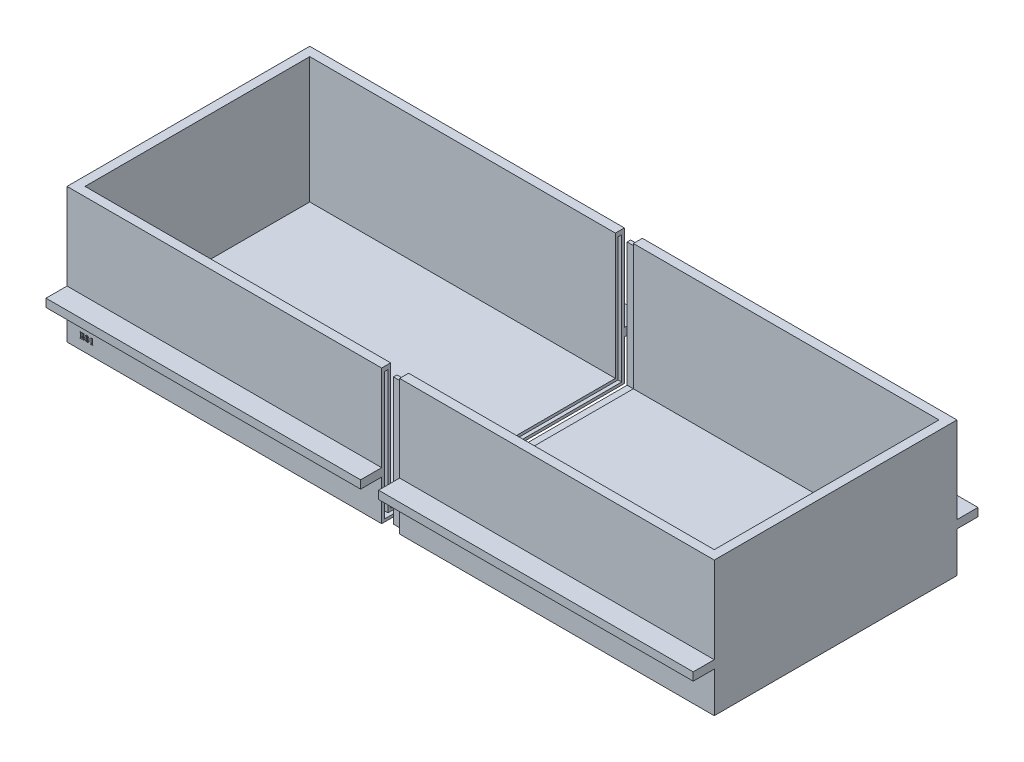
from build123d import *

# Parameters (mm, degrees)
SKETCH1_W                     = 175
SKETCH1_H                     = 135
BOSS_EXTRUDE2_DEPTH           = 75
SKETCH3_W                     = 170
SKETCH3_H                     = 125
CUT_EXTRUDE3_DEPTH            = 70
EXTRUDE_THIN4_DEPTH           = 5
EXTRUDE_THIN4_TAPER           = 0.5
EXTRUDE_THIN4_OTHER_WAY_DEPTH = 1
EXTRUDE_THIN4_OTHER_WAY_TAPER = 1
CUT_EXTRUDE_THIN1_DEPTH       = 241.987551546
CUT_EXTRUDE_THIN1_DEPTH_BACK  = 5
CUT_EXTRUDE6_DEPTH            = 10
SKETCH15_W                    = 175
SKETCH15_H                    = 4.5
BOSS_EXTRUDE3_DEPTH           = 11.7
SKETCH16_W                    = 175
SKETCH16_H                    = 4.5
BOSS_EXTRUDE4_DEPTH           = 11.7
SKETCH17_W                    = 175
SKETCH17_H                    = 4.503667067
BOSS_EXTRUDE5_DEPTH           = 11.7
SKETCH18_W                    = 175
SKETCH18_H                    = 4.5
BOSS_EXTRUDE6_DEPTH           = 11.7


with BuildPart() as part:
    # Sketch1 → Boss-Extrude2 (new body)
    with BuildSketch(Plane(origin=(0, 0, 0), x_dir=(1, 0, 0), z_dir=(0, 1, 0))):
        with Locations((87.5, 67.5)):
            Rectangle(SKETCH1_W, SKETCH1_H)
    extrude(amount=BOSS_EXTRUDE2_DEPTH)

    # Sketch3 → Cut-Extrude3 (cut)
    with BuildSketch(Plane(origin=(0, 75, 0), x_dir=(1, 0, 0), z_dir=(0, 1, 0))):
        with Locations((85, 67.5)):
            Rectangle(SKETCH3_W, SKETCH3_H)
    extrude(amount=-CUT_EXTRUDE3_DEPTH, mode=Mode.SUBTRACT)


with BuildPart() as body_2:
    # Sketch5 → Extrude-Thin4 (new body)
    with BuildSketch(Plane.ZY):
        Polygon((-133.5, 72.5), (-133.5, 1.5), (-1.5, 1.5), (-1.5, 72.5), (-3.5, 72.5), (-3.5, 3.5), (-131.5, 3.5), (-131.5, 72.5), align=None)
    extrude(amount=EXTRUDE_THIN4_DEPTH, taper=EXTRUDE_THIN4_TAPER)

    # Sketch5 → Extrude-Thin4 other way (add)
    with BuildSketch(Plane.ZY):
        Polygon((-133.5, 72.5), (-133.5, 1.5), (-1.5, 1.5), (-1.5, 72.5), (-3.5, 72.5), (-3.5, 3.5), (-131.5, 3.5), (-131.5, 72.5), align=None)
    extrude(amount=-EXTRUDE_THIN4_OTHER_WAY_DEPTH, taper=EXTRUDE_THIN4_OTHER_WAY_TAPER)


with BuildPart() as body_3:
    # Mirror7: mirrored copy
    add(part.part.mirror(Plane(origin=(-5, 0, 0), x_dir=(0, 0, 1), z_dir=(1, 0, 0))))

    # Sketch11 → Cut-Extrude-Thin1 (cut, two sides)
    with BuildSketch(Plane(origin=(-10, 0, 0), x_dir=(0, 0, -1), z_dir=(1, 0, 0))) as cut_extrude_thin1_sk:
        Polygon((1.5, 72.5), (1.5, 1.5), (133.5, 1.5), (133.5, 72.5), (131.5, 72.5), (131.5, 3.5), (3.5, 3.5), (3.5, 72.5), align=None)
    extrude(amount=CUT_EXTRUDE_THIN1_DEPTH, mode=Mode.SUBTRACT)
    extrude(cut_extrude_thin1_sk.sketch, amount=-CUT_EXTRUDE_THIN1_DEPTH_BACK, mode=Mode.SUBTRACT)

    # Sketch13 → Cut-Extrude6 (cut)
    with BuildSketch(Plane.XY):
        with BuildLine():
            Line((-176.616440921, 8.671071982), (-176.616440921, 5.496071982))
            Line((-176.616440921, 5.496071982), (-177.632744089, 5.496071982))
            Line((-177.632744089, 5.496071982), (-177.69337777, 5.496071982))
            add(Edge.make_bspline(
                [(-177.69337777, 5.496071982), (-177.705346361, 5.496468009), (-177.727817325, 5.497211546), (-177.759638375, 5.502718408), (-177.787428818, 5.511979197), (-177.810534198, 5.526028336), (-177.829467076, 5.543433336), (-177.841486357, 5.565357563), (-177.84978866, 5.589882566), (-177.85068737, 5.607384741), (-177.851163143, 5.616650324)],
                knots=[0, 0, 0, 0, 1.275809178, 2.395324508, 3.433364274, 4.378530456, 5.262016052, 6.140052186, 7.015350866, 8, 8, 8, 8], degree=3))
            add(Edge.make_bspline(
                [(-177.851163143, 5.616650324), (-177.850225743, 5.631292422), (-177.848462527, 5.658833677), (-177.831922046, 5.696412103), (-177.803015925, 5.725115324), (-177.778161044, 5.735747942), (-177.765035756, 5.741362781)],
                knots=[0, 0, 0, 0, 1.074896783, 2.021841926, 2.955380476, 4, 4, 4, 4], degree=3))
            add(Edge.make_bspline(
                [(-177.765035756, 5.741362781), (-177.754225698, 5.745222157), (-177.735340256, 5.751964584), (-177.710892127, 5.761296952), (-177.693740648, 5.767252992), (-177.679844251, 5.772605459), (-177.667198156, 5.782716064), (-177.660632574, 5.793210124), (-177.656859758, 5.799240385)],
                knots=[0, 0, 0, 0, 1.641128884, 2.867093284, 3.73955991, 4.239698614, 4.988468111, 6, 6, 6, 6], degree=3))
            add(Edge.make_bspline(
                [(-177.656859758, 5.799240385), (-177.652637239, 5.80621605), (-177.643541415, 5.821242492), (-177.636021582, 5.848683029), (-177.631072029, 5.881041958), (-177.63081585, 5.904403527), (-177.630677032, 5.917062651)],
                knots=[0, 0, 0, 0, 0.795728394, 1.714096871, 2.761318972, 4, 4, 4, 4], degree=3))
            Line((-177.630677032, 5.917062651), (-177.630677032, 8.241813085))
            add(Edge.make_bspline(
                [(-177.630677032, 8.241813085), (-177.630845333, 8.25469561), (-177.631159324, 8.27872999), (-177.635821171, 8.311842767), (-177.643707699, 8.339841156), (-177.652652572, 8.355177866), (-177.656859758, 8.362391427)],
                knots=[0, 0, 0, 0, 1.234380862, 2.302932019, 3.201790819, 4, 4, 4, 4], degree=3))
            add(Edge.make_bspline(
                [(-177.656859758, 8.362391427), (-177.660634584, 8.368416389), (-177.667203662, 8.378901229), (-177.679830806, 8.389061808), (-177.693859505, 8.394296275), (-177.710689479, 8.401327562), (-177.735390239, 8.410224655), (-177.754243893, 8.417050771), (-177.765035756, 8.42095805)],
                knots=[0, 0, 0, 0, 1.009569614, 1.75688657, 2.256055053, 3.138468602, 4.362054748, 6, 6, 6, 6], degree=3))
            add(Edge.make_bspline(
                [(-177.765035756, 8.42095805), (-177.778235914, 8.426499261), (-177.80353883, 8.437121013), (-177.831730258, 8.467367626), (-177.848499642, 8.50553328), (-177.85023882, 8.533541183), (-177.851163143, 8.548426583)],
                knots=[0, 0, 0, 0, 1.03007389, 1.974512116, 2.923511095, 4, 4, 4, 4], degree=3))
            add(Edge.make_bspline(
                [(-177.851163143, 8.548426583), (-177.850676236, 8.557914987), (-177.849755691, 8.575853743), (-177.841650305, 8.600924709), (-177.829447523, 8.62300435), (-177.810556115, 8.640476305), (-177.787286248, 8.654313018), (-177.759802576, 8.664649997), (-177.727791348, 8.669861277), (-177.705337334, 8.670651232), (-177.69337777, 8.671071982)],
                knots=[0, 0, 0, 0, 1.002003185, 1.894384998, 2.766311233, 3.643649008, 4.582238159, 5.621343591, 6.733068665, 8, 8, 8, 8], degree=3))
            Line((-177.69337777, 8.671071982), (-177.632744089, 8.671071982))
            Line((-177.632744089, 8.671071982), (-176.616440921, 8.671071982))
        make_face()
        with BuildLine():
            Line((-176.39595481, 8.671071982), (-175.469913143, 8.671071982))
            Line((-175.469913143, 8.671071982), (-175.469913143, 7.835291818))
            add(Edge.make_bspline(
                [(-175.469913143, 7.835291818), (-175.469958391, 7.82422301), (-175.47004206, 7.803755679), (-175.476131302, 7.775622906), (-175.483686783, 7.751518287), (-175.496452521, 7.732339788), (-175.513083454, 7.717716752), (-175.533749451, 7.708393076), (-175.557931838, 7.701759599), (-175.575507403, 7.701222533), (-175.584979332, 7.700933094)],
                knots=[0, 0, 0, 0, 1.297100046, 2.398467488, 3.37194797, 4.248080405, 5.071011418, 5.940462097, 6.890061477, 8, 8, 8, 8], degree=3))
            add(Edge.make_bspline(
                [(-175.584979332, 7.700933094), (-175.599506049, 7.701826732), (-175.625285577, 7.70341261), (-175.656259278, 7.716301713), (-175.670731633, 7.736387977), (-175.682057286, 7.755357101), (-175.692689619, 7.779977349), (-175.698823646, 7.798492596), (-175.702112579, 7.808420073)],
                knots=[0, 0, 0, 0, 1.496408907, 2.655570162, 3.259085196, 3.998612629, 4.926899124, 6, 6, 6, 6], degree=3))
            add(Edge.make_bspline(
                [(-175.702112579, 7.808420073), (-175.717383026, 7.851565123), (-175.746685576, 7.934356409), (-175.805763599, 8.047562724), (-175.875482195, 8.14433391), (-175.956282018, 8.225500112), (-176.048388272, 8.291272803), (-176.153248274, 8.341023254), (-176.269945451, 8.37747089), (-176.352986897, 8.388874688), (-176.39595481, 8.394775324)],
                knots=[0, 0, 0, 0, 1.130832012, 2.169960077, 3.145894403, 4.069657363, 4.990096479, 5.930045021, 6.928948727, 8, 8, 8, 8], degree=3))
            Line((-176.39595481, 8.394775324), (-176.39595481, 8.671071982))
        make_face()
        with BuildLine():
            Line((-176.39595481, 6.969883831), (-176.39595481, 7.23791226))
            add(Edge.make_bspline(
                [(-176.39595481, 7.23791226), (-176.375624758, 7.248939951), (-176.336763637, 7.270019505), (-176.28314459, 7.303654051), (-176.239423442, 7.340991464), (-176.202037314, 7.37924492), (-176.172552935, 7.423286505), (-176.146985625, 7.472111578), (-176.126386726, 7.527783946), (-176.116513722, 7.567383139), (-176.111389922, 7.587933962)],
                knots=[0, 0, 0, 0, 1.180986571, 2.257469038, 3.222785507, 4.110265038, 4.978639913, 5.917385587, 6.919184056, 8, 8, 8, 8], degree=3))
            add(Edge.make_bspline(
                [(-176.111389922, 7.587933962), (-176.108439891, 7.601784296), (-176.10302178, 7.627222216), (-176.091776741, 7.661538358), (-176.080041894, 7.689242559), (-176.065656379, 7.710734772), (-176.048528802, 7.726333504), (-176.028889141, 7.737762968), (-176.005877856, 7.744004675), (-175.989700178, 7.744676095), (-175.981165313, 7.745030316)],
                knots=[0, 0, 0, 0, 1.505392146, 2.764846178, 3.836585285, 4.697326174, 5.492824879, 6.280783141, 7.092991927, 8, 8, 8, 8], degree=3))
            add(Edge.make_bspline(
                [(-175.981165313, 7.745030316), (-175.970006097, 7.74459074), (-175.948796907, 7.743755283), (-175.920199104, 7.731421745), (-175.897180749, 7.711675982), (-175.887625901, 7.694208562), (-175.882635582, 7.685085654)],
                knots=[0, 0, 0, 0, 1.085852217, 2.06376913, 2.988742716, 4, 4, 4, 4], degree=3))
            add(Edge.make_bspline(
                [(-175.882635582, 7.685085654), (-175.880102235, 7.678255391), (-175.873999653, 7.661801968), (-175.87050041, 7.630934039), (-175.866525384, 7.590799772), (-175.866694213, 7.560624885), (-175.866788143, 7.543836739)],
                knots=[0, 0, 0, 0, 0.609895254, 1.469176849, 2.591947466, 4, 4, 4, 4], degree=3))
            Line((-175.866788143, 7.543836739), (-175.866788143, 6.662581314))
            add(Edge.make_bspline(
                [(-175.866788143, 6.662581314), (-175.867030855, 6.645581407), (-175.867477796, 6.614277017), (-175.871124013, 6.571273225), (-175.8784172, 6.536744385), (-175.888411984, 6.509478405), (-175.903667118, 6.489636004), (-175.923581251, 6.47578978), (-175.948393231, 6.467484627), (-175.96662751, 6.466653611), (-175.976342179, 6.466210871)],
                knots=[0, 0, 0, 0, 1.58411055, 2.917051989, 4.012593196, 4.866950163, 5.598911493, 6.305405458, 7.097171608, 8, 8, 8, 8], degree=3))
            add(Edge.make_bspline(
                [(-175.976342179, 6.466210871), (-175.992120064, 6.467577387), (-176.022236, 6.470185715), (-176.054939347, 6.492695077), (-176.07264477, 6.518745618), (-176.084777982, 6.543694393), (-176.096025184, 6.573881108), (-176.101528266, 6.59613338), (-176.104499731, 6.608148805)],
                knots=[0, 0, 0, 0, 1.342036637, 2.56160375, 3.240040044, 4.033620071, 4.938225671, 6, 6, 6, 6], degree=3))
            add(Edge.make_bspline(
                [(-176.104499731, 6.608148805), (-176.110842747, 6.633582213), (-176.122961309, 6.682173669), (-176.148805335, 6.748868298), (-176.177146725, 6.807156283), (-176.211505697, 6.855443919), (-176.250097298, 6.89558473), (-176.293281902, 6.928621015), (-176.342360627, 6.953879374), (-176.377832599, 6.964472122), (-176.39595481, 6.969883831)],
                knots=[0, 0, 0, 0, 1.278531199, 2.442680666, 3.485773606, 4.434753066, 5.322955403, 6.195374153, 7.078038041, 8, 8, 8, 8], degree=3))
        make_face()
        with BuildLine():
            Line((-176.39595481, 5.496071982), (-176.39595481, 5.752387087))
            add(Edge.make_bspline(
                [(-176.39595481, 5.752387087), (-176.371802756, 5.756545681), (-176.325358431, 5.764542646), (-176.259158789, 5.779314158), (-176.199715053, 5.797538584), (-176.145046604, 5.817263003), (-176.094583054, 5.843226445), (-176.044362369, 5.872961138), (-175.994487177, 5.908635095), (-175.962381882, 5.935672116), (-175.946025339, 5.949446548)],
                knots=[0, 0, 0, 0, 1.178424117, 2.266106011, 3.258322885, 4.167001624, 5.056005255, 5.982165939, 6.971982955, 8, 8, 8, 8], degree=3))
            add(Edge.make_bspline(
                [(-175.946025339, 5.949446548), (-175.914990278, 5.978409283), (-175.85573781, 6.033705242), (-175.794976321, 6.114593429), (-175.754977887, 6.183556307), (-175.726849976, 6.242312699), (-175.698554906, 6.307887163), (-175.681853376, 6.354941071), (-175.673173777, 6.379394465)],
                knots=[0, 0, 0, 0, 1.478913818, 2.823557948, 3.509390326, 4.258413643, 5.094916917, 6, 6, 6, 6], degree=3))
            add(Edge.make_bspline(
                [(-175.673173777, 6.379394465), (-175.668953175, 6.391160153), (-175.661157695, 6.412891461), (-175.648341811, 6.442223181), (-175.634617881, 6.465125982), (-175.616341175, 6.48808462), (-175.585093693, 6.507149), (-175.557026785, 6.509219013), (-175.542260148, 6.510308094)],
                knots=[0, 0, 0, 0, 1.119865357, 2.068399023, 2.86239926, 3.505232302, 4.687446157, 6, 6, 6, 6], degree=3))
            add(Edge.make_bspline(
                [(-175.542260148, 6.510308094), (-175.532130163, 6.509707605), (-175.513212385, 6.50858619), (-175.486829232, 6.502294364), (-175.465877099, 6.489253454), (-175.449665696, 6.470885873), (-175.439008257, 6.446047246), (-175.430754245, 6.41524378), (-175.426329329, 6.37721835), (-175.425995901, 6.349545644), (-175.425815921, 6.334608224)],
                knots=[0, 0, 0, 0, 0.999578033, 1.866714988, 2.638932701, 3.392362113, 4.242509345, 5.27434009, 6.528718957, 8, 8, 8, 8], degree=3))
            Line((-175.425815921, 6.334608224), (-175.425815921, 5.496071982))
            Line((-175.425815921, 5.496071982), (-176.39595481, 5.496071982))
        make_face()
        with BuildLine():
            add(Edge.make_bspline(
                [(-174.01470481, 5.457486913), (-174.054356273, 5.463376377), (-174.131889647, 5.47489247), (-174.24390388, 5.504964767), (-174.348760088, 5.545073959), (-174.448074077, 5.594420466), (-174.54214204, 5.65489762), (-174.63105306, 5.728416516), (-174.717999568, 5.812395184), (-174.770479837, 5.876086463), (-174.797430504, 5.908794422)],
                knots=[0, 0, 0, 0, 1.034782028, 2.023384117, 2.988532632, 3.930372206, 4.883152863, 5.869902034, 6.906111536, 8, 8, 8, 8], degree=3))
            add(Edge.make_bspline(
                [(-174.797430504, 5.908794422), (-174.826313554, 5.947029194), (-174.88450205, 6.024057896), (-174.956720633, 6.151422436), (-175.020296858, 6.287062087), (-175.071108496, 6.432469923), (-175.112444577, 6.5857186), (-175.139375256, 6.746384243), (-175.158722726, 6.913374819), (-175.160385066, 7.027013106), (-175.161232587, 7.084950021)],
                knots=[0, 0, 0, 0, 0.915815346, 1.845023881, 2.794496633, 3.778408421, 4.787686839, 5.827165717, 6.892210385, 8, 8, 8, 8], degree=3))
            add(Edge.make_bspline(
                [(-175.161232587, 7.084950021), (-175.16036541, 7.142426025), (-175.158657854, 7.255601892), (-175.139449723, 7.421921272), (-175.11235001, 7.582326956), (-175.071117677, 7.735364631), (-175.020294518, 7.880770497), (-174.956721233, 8.01641065), (-174.884501904, 8.143775063), (-174.826313506, 8.220803782), (-174.797430504, 8.259038562)],
                knots=[0, 0, 0, 0, 1.100810489, 2.167603378, 3.204454396, 4.215389498, 5.200916332, 6.151947599, 7.082681386, 8, 8, 8, 8], degree=3))
            add(Edge.make_bspline(
                [(-174.797430504, 8.259038562), (-174.770479837, 8.291746521), (-174.717999568, 8.3554378), (-174.63105306, 8.439416468), (-174.54214204, 8.512935364), (-174.448074077, 8.573412518), (-174.348760088, 8.622759025), (-174.24390388, 8.662868217), (-174.131889647, 8.692940514), (-174.054356273, 8.704456607), (-174.01470481, 8.710346071)],
                knots=[0, 0, 0, 0, 1.093888464, 2.130097966, 3.116847137, 4.069627794, 5.011467368, 5.976615883, 6.965217972, 8, 8, 8, 8], degree=3))
            Line((-174.01470481, 8.710346071), (-174.01470481, 8.465744291))
            add(Edge.make_bspline(
                [(-174.01470481, 8.465744291), (-174.025536222, 8.462406306), (-174.045464881, 8.456264764), (-174.072181262, 8.446388019), (-174.094110348, 8.438424418), (-174.116265603, 8.427517391), (-174.139998497, 8.409766614), (-174.155355657, 8.392340787), (-174.163532935, 8.383062)],
                knots=[0, 0, 0, 0, 1.175556867, 2.162900895, 2.954972592, 3.59433869, 4.719049707, 6, 6, 6, 6], degree=3))
            add(Edge.make_bspline(
                [(-174.163532935, 8.383062), (-174.174528424, 8.367124396), (-174.197329112, 8.334075541), (-174.219874018, 8.27439719), (-174.232443085, 8.205373532), (-174.23424024, 8.15620287), (-174.235190921, 8.130191991)],
                knots=[0, 0, 0, 0, 0.865850794, 1.795462935, 2.833817886, 4, 4, 4, 4], degree=3))
            Line((-174.235190921, 8.130191991), (-174.235190921, 6.025927668))
            add(Edge.make_bspline(
                [(-174.235190921, 6.025927668), (-174.234274924, 6.000366566), (-174.232552948, 5.952314427), (-174.219628916, 5.884754294), (-174.197509233, 5.826255965), (-174.174548905, 5.794030862), (-174.163532935, 5.778569812)],
                knots=[0, 0, 0, 0, 1.168345534, 2.196364665, 3.134646847, 4, 4, 4, 4], degree=3))
            add(Edge.make_bspline(
                [(-174.163532935, 5.778569812), (-174.155340236, 5.76954642), (-174.139946882, 5.752592266), (-174.116386694, 5.735109498), (-174.093762395, 5.725615058), (-174.07254039, 5.716148548), (-174.045253109, 5.707792284), (-174.025486823, 5.701426793), (-174.01470481, 5.697954578)],
                knots=[0, 0, 0, 0, 1.272322127, 2.39058029, 3.023908165, 3.830309867, 4.816488449, 6, 6, 6, 6], degree=3))
            Line((-174.01470481, 5.697954578), (-174.01470481, 5.457486913))
        make_face()
        with BuildLine():
            Line((-173.838315921, 5.457486913), (-173.838315921, 5.697954578))
            add(Edge.make_bspline(
                [(-173.838315921, 5.697954578), (-173.827530941, 5.701420825), (-173.807759217, 5.707775374), (-173.780505502, 5.716199173), (-173.759380188, 5.725393047), (-173.737101101, 5.735537058), (-173.713086597, 5.752269266), (-173.697641205, 5.769482947), (-173.689487796, 5.778569812)],
                knots=[0, 0, 0, 0, 1.183923098, 2.170444609, 2.977126724, 3.588941393, 4.727235443, 6, 6, 6, 6], degree=3))
            add(Edge.make_bspline(
                [(-173.689487796, 5.778569812), (-173.678114479, 5.793972117), (-173.654541207, 5.825896199), (-173.633880911, 5.885043253), (-173.61927985, 5.952157524), (-173.618332921, 6.000332111), (-173.61782981, 6.025927668)],
                knots=[0, 0, 0, 0, 0.870389709, 1.80404125, 2.833268942, 4, 4, 4, 4], degree=3))
            Line((-173.61782981, 6.025927668), (-173.61782981, 8.130191991))
            add(Edge.make_bspline(
                [(-173.61782981, 8.130191991), (-173.618368483, 8.156236466), (-173.619387949, 8.205526885), (-173.633640065, 8.27411125), (-173.654716132, 8.334430588), (-173.678133885, 8.367182498), (-173.689487796, 8.383062)],
                knots=[0, 0, 0, 0, 1.164647241, 2.204150809, 3.129296843, 4, 4, 4, 4], degree=3))
            add(Edge.make_bspline(
                [(-173.689487796, 8.383062), (-173.697622553, 8.392406259), (-173.713022234, 8.410095615), (-173.737246965, 8.427072752), (-173.759025467, 8.438639654), (-173.780868311, 8.446333779), (-173.807546236, 8.456282841), (-173.827481123, 8.462412671), (-173.838315921, 8.465744291)],
                knots=[0, 0, 0, 0, 1.28136681, 2.425719814, 3.044066562, 3.836395811, 4.824060886, 6, 6, 6, 6], degree=3))
            Line((-173.838315921, 8.465744291), (-173.838315921, 8.710346071))
            add(Edge.make_bspline(
                [(-173.838315921, 8.710346071), (-173.798664457, 8.704456607), (-173.721131083, 8.692940514), (-173.60911685, 8.662868217), (-173.504260642, 8.622759025), (-173.404946653, 8.573412518), (-173.310878691, 8.512935364), (-173.22196767, 8.439416468), (-173.135021162, 8.3554378), (-173.082540893, 8.291746521), (-173.055590226, 8.259038562)],
                knots=[0, 0, 0, 0, 1.034782028, 2.023384117, 2.988532632, 3.930372206, 4.883152863, 5.869902034, 6.906111536, 8, 8, 8, 8], degree=3))
            add(Edge.make_bspline(
                [(-173.055590226, 8.259038562), (-173.026724008, 8.220796122), (-172.968569424, 8.14375197), (-172.89613955, 8.016589326), (-172.833612571, 7.880577985), (-172.782471018, 7.735403218), (-172.741603571, 7.582237616), (-172.713320555, 7.422008441), (-172.694429789, 7.255589577), (-172.692677856, 7.142421878), (-172.691788143, 7.084950021)],
                knots=[0, 0, 0, 0, 0.917441318, 1.848299604, 2.797612926, 3.783271587, 4.794341916, 5.832106675, 6.899042262, 8, 8, 8, 8], degree=3))
            add(Edge.make_bspline(
                [(-172.691788143, 7.084950021), (-172.692658344, 7.027017263), (-172.694365168, 6.913387131), (-172.713395987, 6.746297608), (-172.741508233, 6.585807472), (-172.782480544, 6.432431446), (-172.833610148, 6.287254572), (-172.896140172, 6.151243768), (-172.968569272, 6.024080987), (-173.026723958, 5.947036853), (-173.055590226, 5.908794422)],
                knots=[0, 0, 0, 0, 1.107938, 2.173125328, 3.213514, 4.222927608, 5.206971189, 6.154728984, 7.084061984, 8, 8, 8, 8], degree=3))
            add(Edge.make_bspline(
                [(-173.055590226, 5.908794422), (-173.082540893, 5.876086463), (-173.135021162, 5.812395184), (-173.22196767, 5.728416516), (-173.310878691, 5.65489762), (-173.404946653, 5.594420466), (-173.504260642, 5.545073959), (-173.60911685, 5.504964767), (-173.721131083, 5.47489247), (-173.798664457, 5.463376377), (-173.838315921, 5.457486913)],
                knots=[0, 0, 0, 0, 1.093888464, 2.130097966, 3.116847137, 4.069627794, 5.011467368, 5.976615883, 6.965217972, 8, 8, 8, 8], degree=3))
        make_face()
        with BuildLine():
            Line((-170.751510365, 8.671071982), (-170.751510365, 5.935666166))
            add(Edge.make_bspline(
                [(-170.751510365, 5.935666166), (-170.751390235, 5.921577257), (-170.751167482, 5.895452767), (-170.742609157, 5.859887196), (-170.733107027, 5.828928124), (-170.720321681, 5.813427204), (-170.714303334, 5.806130576)],
                knots=[0, 0, 0, 0, 1.221894812, 2.265709648, 3.183630964, 4, 4, 4, 4], degree=3))
            add(Edge.make_bspline(
                [(-170.714303334, 5.806130576), (-170.70819496, 5.799568437), (-170.697372815, 5.787942359), (-170.679314933, 5.777222656), (-170.659989401, 5.772056893), (-170.635807188, 5.767154775), (-170.602411034, 5.757363787), (-170.576540995, 5.751526943), (-170.562030113, 5.748252972)],
                knots=[0, 0, 0, 0, 0.967781164, 1.714608312, 2.234126727, 3.127399629, 4.388716669, 6, 6, 6, 6], degree=3))
            add(Edge.make_bspline(
                [(-170.562030113, 5.748252972), (-170.544092172, 5.743680151), (-170.51108727, 5.735266393), (-170.471166997, 5.70644804), (-170.446515781, 5.666612335), (-170.444095666, 5.636522902), (-170.44282981, 5.620784439)],
                knots=[0, 0, 0, 0, 1.155259645, 2.125619132, 3.019593567, 4, 4, 4, 4], degree=3))
            add(Edge.make_bspline(
                [(-170.44282981, 5.620784439), (-170.44368946, 5.61126121), (-170.445412756, 5.592170483), (-170.457666318, 5.564805727), (-170.47956081, 5.541735249), (-170.497889793, 5.529900784), (-170.507597605, 5.523632746)],
                knots=[0, 0, 0, 0, 0.931770353, 1.867872026, 2.870733925, 4, 4, 4, 4], degree=3))
            add(Edge.make_bspline(
                [(-170.507597605, 5.523632746), (-170.516680663, 5.519450315), (-170.536762791, 5.510203194), (-170.572619897, 5.50162208), (-170.616128706, 5.497455516), (-170.647688648, 5.496556432), (-170.664693959, 5.496071982)],
                knots=[0, 0, 0, 0, 0.744408225, 1.645844579, 2.731520362, 4, 4, 4, 4], degree=3))
            Line((-170.664693959, 5.496071982), (-170.749443308, 5.496071982))
            Line((-170.749443308, 5.496071982), (-171.635521867, 5.496071982))
            Line((-171.635521867, 5.496071982), (-171.706490834, 5.496071982))
            add(Edge.make_bspline(
                [(-171.706490834, 5.496071982), (-171.721432396, 5.496551736), (-171.749105252, 5.497440276), (-171.787131318, 5.50164037), (-171.818114557, 5.510065303), (-171.834775989, 5.519440025), (-171.842227596, 5.523632746)],
                knots=[0, 0, 0, 0, 1.278909849, 2.36863365, 3.270392795, 4, 4, 4, 4], degree=3))
            add(Edge.make_bspline(
                [(-171.842227596, 5.523632746), (-171.850555352, 5.52996664), (-171.866580351, 5.542154873), (-171.885377158, 5.565359109), (-171.89605113, 5.592379474), (-171.897373389, 5.611281579), (-171.898038143, 5.620784439)],
                knots=[0, 0, 0, 0, 1.071870055, 2.062586414, 3.025983099, 4, 4, 4, 4], degree=3))
            add(Edge.make_bspline(
                [(-171.898038143, 5.620784439), (-171.897218759, 5.636495643), (-171.895667097, 5.666247839), (-171.873562198, 5.705036065), (-171.839809051, 5.735130209), (-171.810442254, 5.743670575), (-171.794685278, 5.748252972)],
                knots=[0, 0, 0, 0, 1.041821617, 1.972890251, 2.912339053, 4, 4, 4, 4], degree=3))
            add(Edge.make_bspline(
                [(-171.794685278, 5.748252972), (-171.782002617, 5.751520056), (-171.759538926, 5.757306758), (-171.73100131, 5.766991989), (-171.710500404, 5.772130162), (-171.69406904, 5.777313002), (-171.678734198, 5.788013477), (-171.670503336, 5.799577158), (-171.665838707, 5.806130576)],
                knots=[0, 0, 0, 0, 1.624637859, 2.877579422, 3.734891967, 4.248647568, 5.007466236, 6, 6, 6, 6], degree=3))
            add(Edge.make_bspline(
                [(-171.665838707, 5.806130576), (-171.660567695, 5.813487518), (-171.649202787, 5.829349929), (-171.640941101, 5.859956203), (-171.634221958, 5.895621114), (-171.633724177, 5.921605203), (-171.63345481, 5.935666166)],
                knots=[0, 0, 0, 0, 0.793417505, 1.710699182, 2.761173524, 4, 4, 4, 4], degree=3))
            Line((-171.63345481, 5.935666166), (-171.63345481, 8.106765342))
            add(Edge.make_bspline(
                [(-171.63345481, 8.106765342), (-171.633617843, 8.125841602), (-171.633920975, 8.161310468), (-171.638614056, 8.210420029), (-171.646330114, 8.251523612), (-171.658204377, 8.284652605), (-171.672583993, 8.311430025), (-171.691487545, 8.331416033), (-171.714888759, 8.344601031), (-171.732063227, 8.348152899), (-171.740941789, 8.349989083)],
                knots=[0, 0, 0, 0, 1.573891919, 2.926368201, 4.067733782, 5.015207088, 5.82171764, 6.559095732, 7.255106106, 8, 8, 8, 8], degree=3))
            Line((-171.740941789, 8.349989083), (-171.827069176, 8.361702408))
            add(Edge.make_bspline(
                [(-171.827069176, 8.361702408), (-171.844225005, 8.36492243), (-171.875511064, 8.370794592), (-171.914565248, 8.395431127), (-171.939269975, 8.432073761), (-171.941153213, 8.460543116), (-171.942135365, 8.475390559)],
                knots=[0, 0, 0, 0, 1.161059911, 2.117355492, 3.018156337, 4, 4, 4, 4], degree=3))
            add(Edge.make_bspline(
                [(-171.942135365, 8.475390559), (-171.941580445, 8.487528255), (-171.940503477, 8.511084657), (-171.924955787, 8.543079614), (-171.903370377, 8.572273567), (-171.882732886, 8.585985586), (-171.871855417, 8.593212824)],
                knots=[0, 0, 0, 0, 1.003758752, 1.948058634, 2.918476655, 4, 4, 4, 4], degree=3))
            add(Edge.make_bspline(
                [(-171.871855417, 8.593212824), (-171.864592939, 8.596473041), (-171.847432413, 8.604176614), (-171.814972664, 8.60959205), (-171.774011937, 8.616354946), (-171.743280794, 8.618320494), (-171.726472388, 8.61939555)],
                knots=[0, 0, 0, 0, 0.641016437, 1.514659076, 2.640642126, 4, 4, 4, 4], degree=3))
            Line((-171.726472388, 8.61939555), (-170.751510365, 8.671071982))
        make_face()
    extrude(amount=-CUT_EXTRUDE6_DEPTH, mode=Mode.SUBTRACT)

    # Sketch15 → Boss-Extrude3 (add)
    with BuildSketch(Plane.XY):
        with Locations((-97.5, 24.75)):
            Rectangle(SKETCH15_W, SKETCH15_H)
    extrude(amount=BOSS_EXTRUDE3_DEPTH)

    # Sketch18 → Boss-Extrude6 (add)
    with BuildSketch(Plane(origin=(0, 0, -135), x_dir=(-1, 0, 0), z_dir=(0, 0, -1))):
        with Locations((97.5, 24.75)):
            Rectangle(SKETCH18_W, SKETCH18_H)
    extrude(amount=BOSS_EXTRUDE6_DEPTH)


with BuildPart() as part_1:
    add(part.part)

    # Sketch16 → Boss-Extrude4 (add)
    with BuildSketch(Plane.XY):
        with Locations((87.5, 24.75)):
            Rectangle(SKETCH16_W, SKETCH16_H)
    extrude(amount=BOSS_EXTRUDE4_DEPTH)

    # Sketch17 → Boss-Extrude5 (add)
    with BuildSketch(Plane(origin=(0, 0, -135), x_dir=(-1, 0, 0), z_dir=(0, 0, -1))):
        with Locations((-87.5, 24.748166467)):
            Rectangle(SKETCH17_W, SKETCH17_H)
    extrude(amount=BOSS_EXTRUDE5_DEPTH)


solid = Compound([body_2.part, body_3.part, part_1.part])
